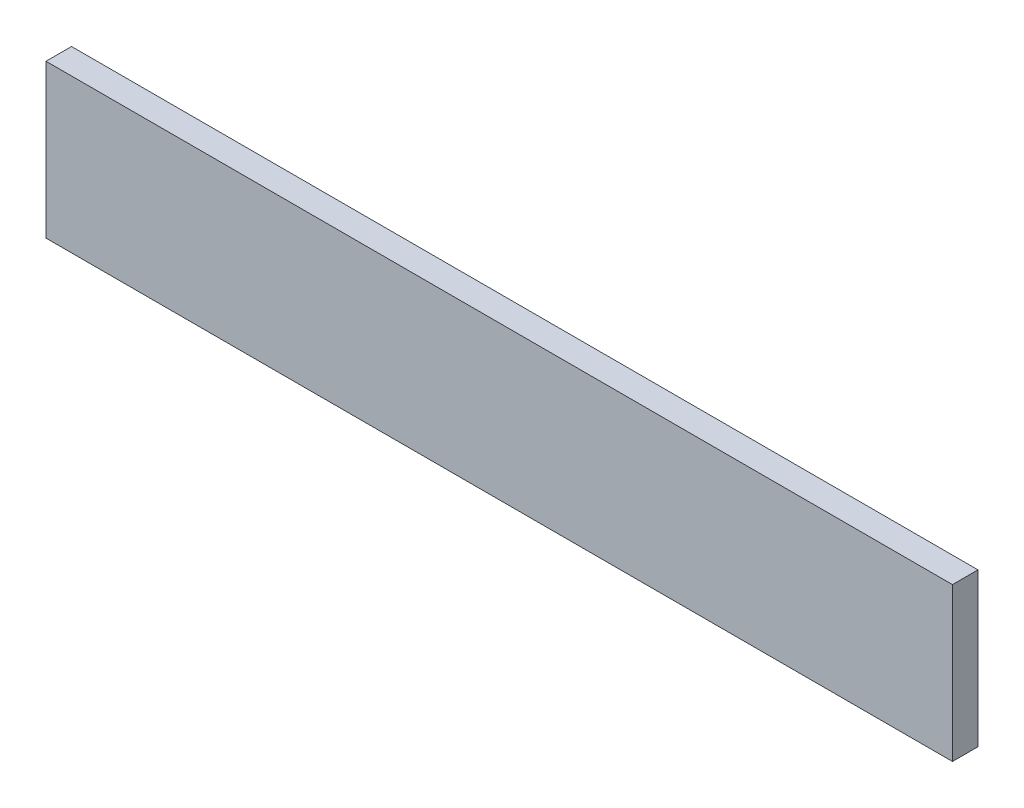
from build123d import *

# Parameters (mm, degrees)
SKETCH1_W           = 710
SKETCH1_H           = 120
BOSS_EXTRUDE1_DEPTH = 20


with BuildPart() as part:
    # Sketch1 → Boss-Extrude1 (new body)
    with BuildSketch(Plane.XY):
        with Locations((355, 60)):
            Rectangle(SKETCH1_W, SKETCH1_H)
    extrude(amount=BOSS_EXTRUDE1_DEPTH)


solid = part.part
